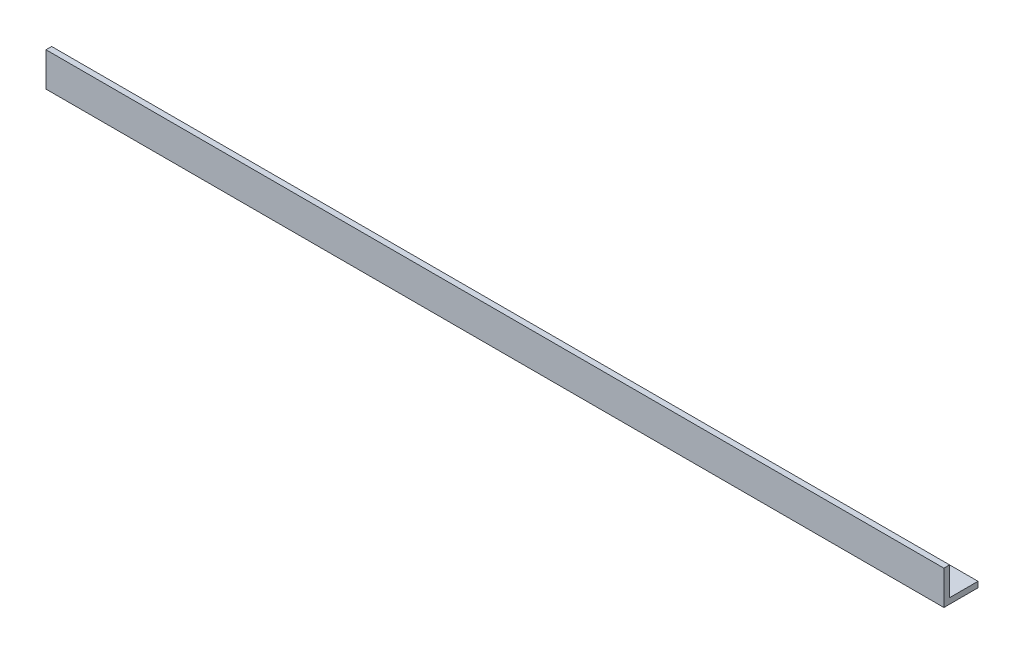
from build123d import *

# Parameters (mm, degrees)
BOSS_EXTRUDE1_DEPTH = 39.5


with BuildPart() as part:
    # Sketch1 → Boss-Extrude1 (new body)
    with BuildSketch(Plane(origin=(0, 0, 0), x_dir=(0, 0, -1), z_dir=(1, 0, 0))):
        Polygon((0, 0), (0, 1.25), (-0.25, 1.25), (-0.25, -0.25), (1.25, -0.25), (1.25, 0), align=None)
    extrude(amount=BOSS_EXTRUDE1_DEPTH)


solid = part.part
